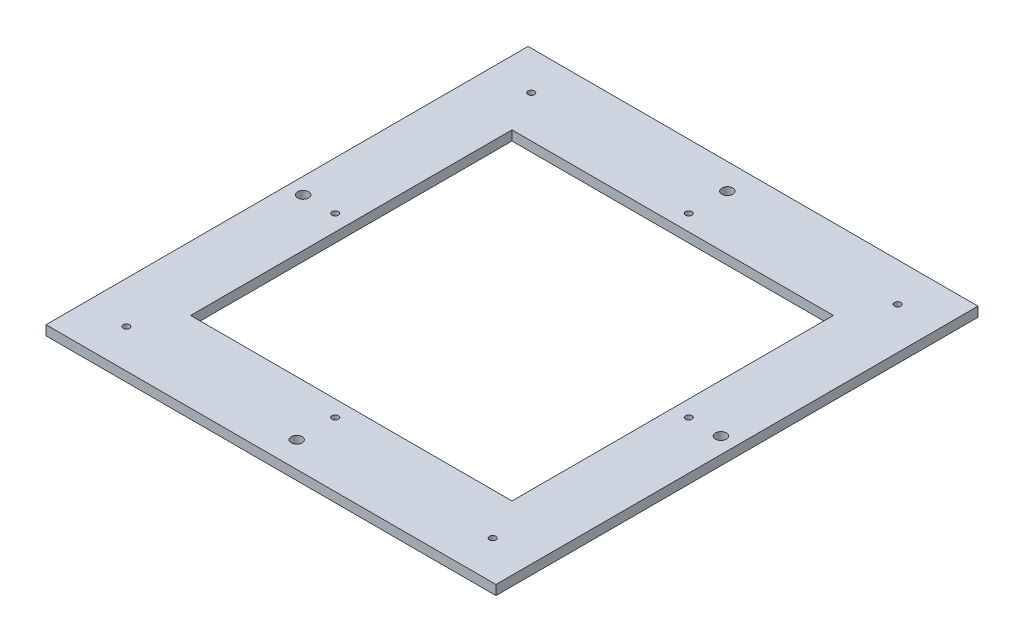
from build123d import *

# Parameters (mm, degrees)
SKETCH_1_W           = 140
SKETCH_1_H           = 3
EXTRUDE_1_DEPTH      = 150
CUT_EXTRUDE_1_REACH  = 5
SKETCH_2_W           = 100
SKETCH_2_H           = 100
HOLE_WIZARD_M3_1_D   = 3.4
HOLE_WIZARD_M3_1_2_D = 2


with BuildPart() as part:
    # 草图1 → 拉伸-薄壁1 (new body)
    with BuildSketch(Plane.XY):
        with Locations((82, 225.557982809)):
            Rectangle(SKETCH_1_W, SKETCH_1_H)
    extrude(amount=EXTRUDE_1_DEPTH)

    # 草图2 → 切除-拉伸1 (cut, up to next)
    with BuildSketch(Plane.XZ.offset(-224.057982809), mode=Mode.PRIVATE) as cut_extrude_1_sk1:
        with Locations((82, 75)):
            Rectangle(SKETCH_2_W, SKETCH_2_H)
    cut_extrude_1_tool1 = extrude(cut_extrude_1_sk1.sketch, amount=-CUT_EXTRUDE_1_REACH, mode=Mode.PRIVATE) & part.part
    add(cut_extrude_1_tool1.solids().sort_by_distance((82, 224.057983, 75))[0], mode=Mode.SUBTRACT)

    # Hole Wizard M3 _1 (through all)
    with Locations(Plane(origin=(0, 224.057982809, 0), x_dir=(-1, 0, 0), z_dir=(0, -1, 0))):
        with Locations((-82, -142), (-147, -75), (-82, -8), (-17, -75)):
            Hole(HOLE_WIZARD_M3_1_D / 2)

    # Hole Wizard M3 _1 2 (through all)
    with Locations(Plane(origin=(0, 224.057982809, 0), x_dir=(-1, 0, 0), z_dir=(0, -1, 0))):
        with Locations((-139, -138), (-25, -138), (-82, -130), (-27, -75), (-137, -75), (-82, -20), (-25, -12), (-139, -12)):
            Hole(HOLE_WIZARD_M3_1_2_D / 2)


solid = part.part
